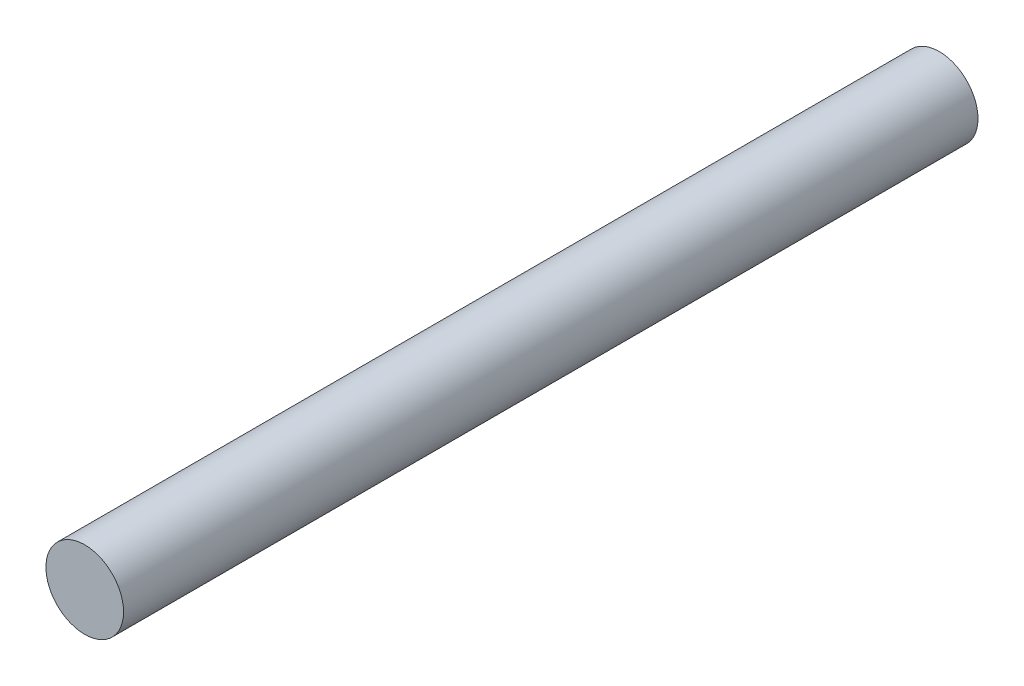
from build123d import *

# Parameters (mm, degrees)
SKETCH2_R           = 15.9
BOSS_EXTRUDE1_DEPTH = 350


with BuildPart() as part:
    # Sketch2 → Boss-Extrude1 (new body)
    with BuildSketch(Plane.XY):
        Circle(SKETCH2_R)
    extrude(amount=BOSS_EXTRUDE1_DEPTH)


solid = part.part
